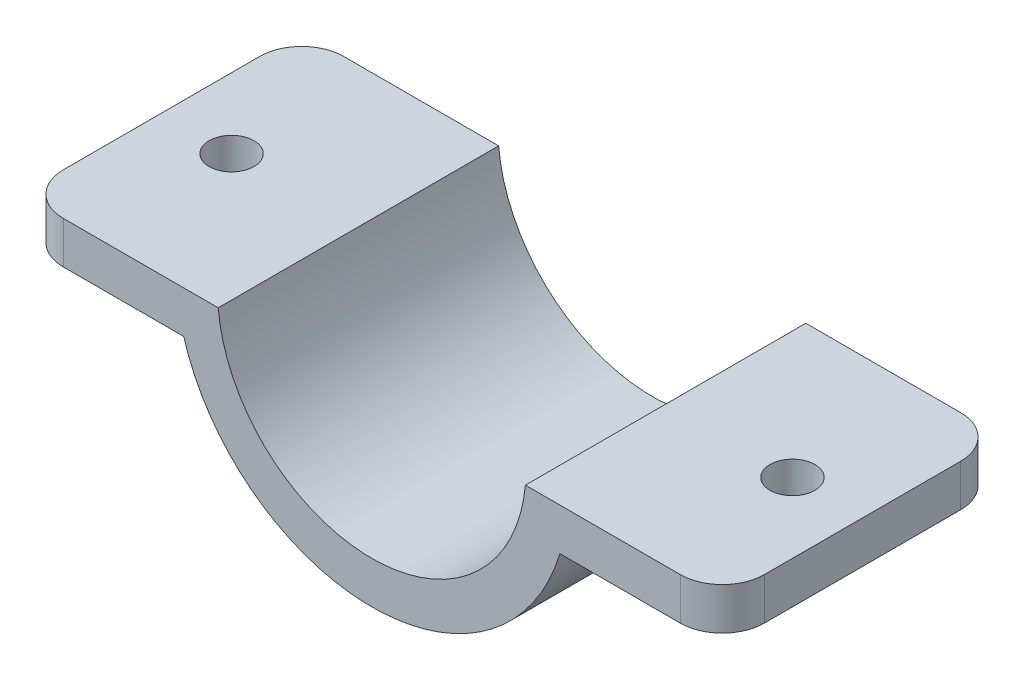
from build123d import *

# Parameters (mm, degrees)
BOSS_EXTRUDE1_DEPTH = 20
SKETCH2_R           = 1.6
CUT_EXTRUDE1_DEPTH  = 20
FILLET1_R           = 3


with BuildPart() as part:
    # Sketch1 → Boss-Extrude1 (new body)
    with BuildSketch(Plane.XY):
        with BuildLine():
            Line((-10.95445115, -1), (-13.964240044, -1))
            ThreePointArc((-13.964240044, -1), (-13.772253627, -2.514961237), (-13.416407865, -4))
            ThreePointArc((-13.416407865, -4), (0, -14), (13.416407865, -4))
            ThreePointArc((13.416407865, -4), (13.772253627, -2.514961237), (13.964240044, -1))
            Line((13.964240044, -1), (10.95445115, -1))
            ThreePointArc((10.95445115, -1), (0, -11), (-10.95445115, -1))
        make_face()
        with BuildLine():
            Line((-13.964240044, -1), (-25, -1))
            Line((-25, -1), (-25, -4))
            Line((-25, -4), (-13.416407865, -4))
            ThreePointArc((-13.416407865, -4), (-13.772253627, -2.514961237), (-13.964240044, -1))
        make_face()
        with BuildLine():
            Line((25, -1), (13.964240044, -1))
            ThreePointArc((13.964240044, -1), (13.772253627, -2.514961237), (13.416407865, -4))
            Line((13.416407865, -4), (25, -4))
            Line((25, -4), (25, -1))
        make_face()
    extrude(amount=BOSS_EXTRUDE1_DEPTH)

    # Sketch2 → Cut-Extrude1 (cut)
    with BuildSketch(Plane.XZ.offset(4)):
        with Locations((-20, 10)):
            Circle(SKETCH2_R)
    cut_extrude1 = extrude(amount=-CUT_EXTRUDE1_DEPTH, mode=Mode.SUBTRACT)

    # Mirror1: Cut-Extrude1 across plane
    add(cut_extrude1.mirror(Plane(origin=(0, 0, 0), x_dir=(0, 0, 1), z_dir=(1, 0, 0))), mode=Mode.SUBTRACT)

    # Fillet1
    fillet1_edges = [part.edges().sort_by_distance(p)[0] for p in [
        (-25, -2.5, 0),
        (-25, -2.5, 20),
        (25, -2.5, 20),
        (25, -2.5, 0),
    ]]
    fillet(fillet1_edges, radius=FILLET1_R)


solid = part.part
